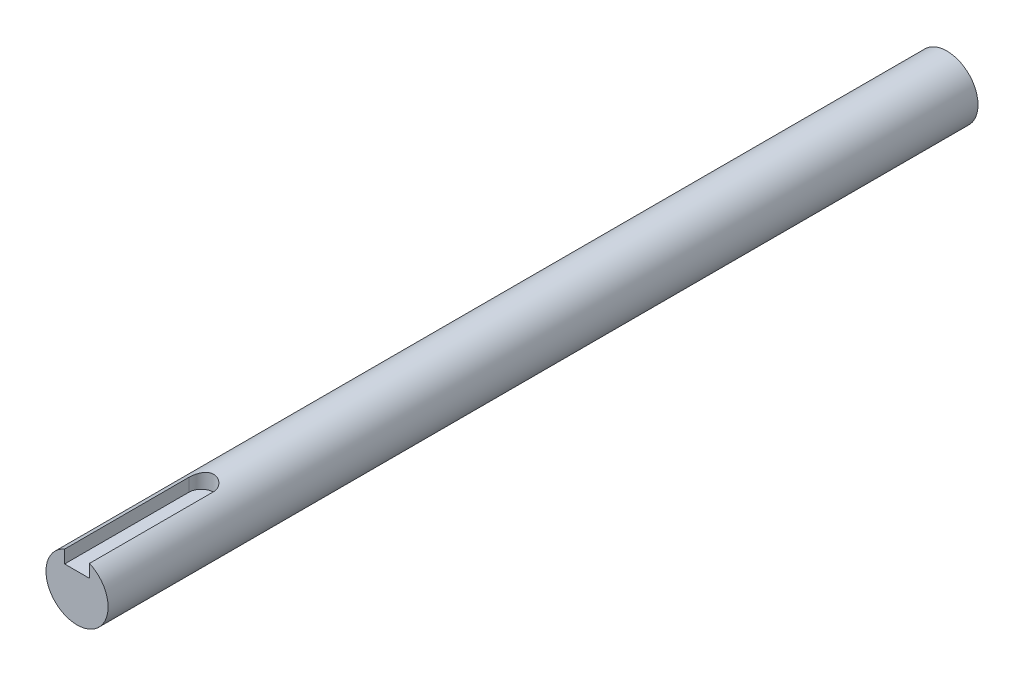
from build123d import *

# Parameters (mm, degrees)
BOSS_EXTRUDE1_DEPTH = 20
BOSS_EXTRUDE2_START = -120
SKETCH1_3_R         = 5
BOSS_EXTRUDE2_DEPTH = 120
SKETCH4_W           = 2
SKETCH4_H           = 2.701125373


with BuildPart() as part:
    # Sketch1 → Boss-Extrude1 (new body)
    with BuildSketch(Plane.XY):
        with BuildLine():
            Line((2, 2.5), (0, 2.5))
            Line((0, 2.5), (-2, 2.5))
            Line((-2, 2.5), (-2, 4.582575695))
            ThreePointArc((-2, 4.582575695), (-2.738612788, -4.183300133), (5, 0))
            ThreePointArc((5, 0), (4.183300133, 2.738612788), (2, 4.582575695))
            Line((2, 4.582575695), (2, 2.5))
        make_face()
    extrude(amount=BOSS_EXTRUDE1_DEPTH)

    # Sketch1_3 → Boss-Extrude2 (add)
    with BuildSketch(Plane.XY.offset(BOSS_EXTRUDE2_START)):
        Circle(SKETCH1_3_R)
    extrude(amount=BOSS_EXTRUDE2_DEPTH)

    # Sketch4 → Cut-Revolve2 (revolve, cut)
    with BuildSketch(Plane.XY):
        with Locations((1, 3.850562686)):
            Rectangle(SKETCH4_W, SKETCH4_H)
    revolve(axis=Axis((0, 0, 0), (0, 1, 0)), mode=Mode.SUBTRACT)


solid = part.part
